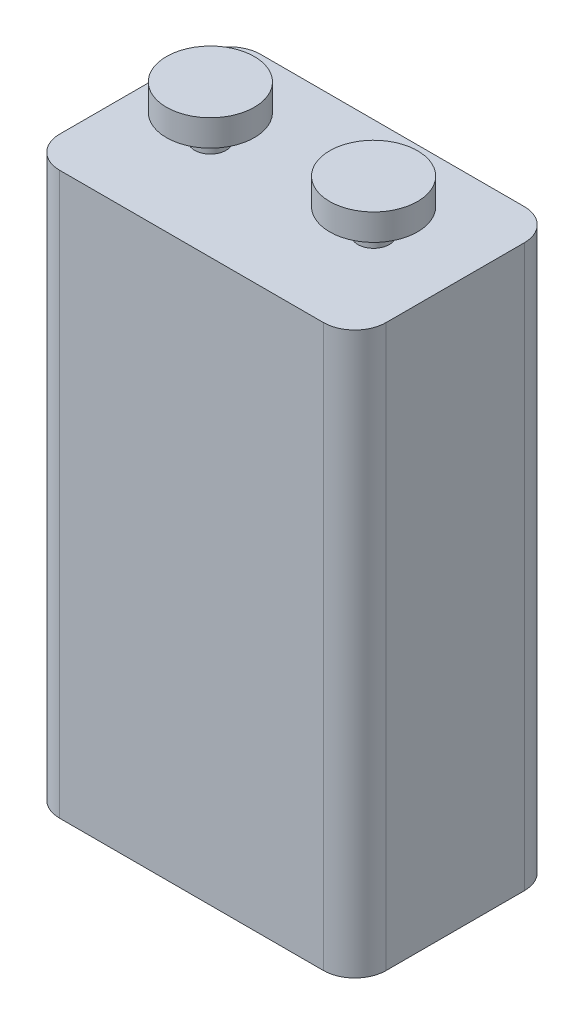
from build123d import *

# Parameters (mm, degrees)
BOSS_EXTRUDE1_DEPTH = 44.7
SKETCH2_R           = 1.25
BOSS_EXTRUDE2_DEPTH = 4.1
SKETCH3_R           = 3.5
BOSS_EXTRUDE3_DEPTH = 2.1


with BuildPart() as part:
    # Sketch1 → Boss-Extrude1 (new body)
    with BuildSketch(Plane(origin=(0, 0, 0), x_dir=(1, 0, 0), z_dir=(0, 1, 0))):
        with BuildLine():
            Line((-10.5, 8), (10.5, 8))
            ThreePointArc((10.5, 8), (12.267766953, 7.267766953), (13, 5.5))
            Line((13, 5.5), (13, -5.5))
            ThreePointArc((13, -5.5), (12.267766953, -7.267766953), (10.5, -8))
            Line((10.5, -8), (-10.5, -8))
            ThreePointArc((-10.5, -8), (-12.267766953, -7.267766953), (-13, -5.5))
            Line((-13, -5.5), (-13, 5.5))
            ThreePointArc((-13, 5.5), (-12.267766953, 7.267766953), (-10.5, 8))
        make_face()
    extrude(amount=BOSS_EXTRUDE1_DEPTH)

    # Sketch2 → Boss-Extrude2 (add)
    with BuildSketch(Plane(origin=(0, 44.7, 0), x_dir=(1, 0, 0), z_dir=(0, 1, 0))):
        with Locations((-6.5, 0)):
            Circle(SKETCH2_R)
        with Locations((6.5, 0)):
            Circle(SKETCH2_R)
    extrude(amount=BOSS_EXTRUDE2_DEPTH)

    # Sketch3 → Boss-Extrude3 (add)
    with BuildSketch(Plane(origin=(0, 48.8, 0), x_dir=(1, 0, 0), z_dir=(0, 1, 0))):
        with Locations((-6.5, 0)):
            Circle(SKETCH3_R)
        with Locations((6.5, 0)):
            Circle(SKETCH3_R)
    extrude(amount=-BOSS_EXTRUDE3_DEPTH)


solid = part.part
